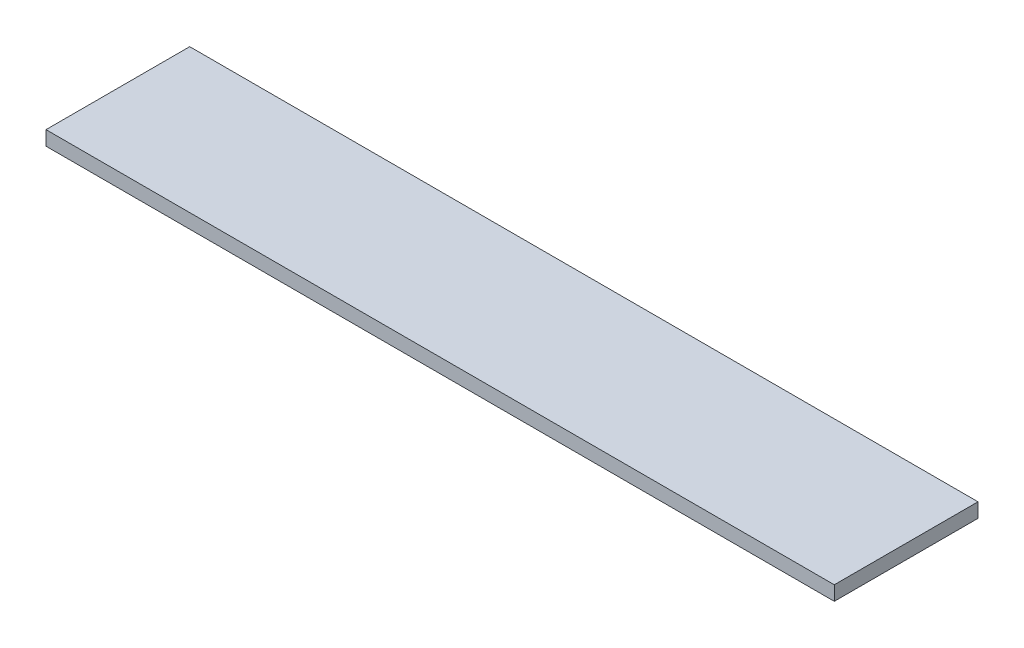
from build123d import *

# Parameters (mm, degrees)
SKETCH1_W           = 548.53
SKETCH1_H           = 100
BOSS_EXTRUDE1_DEPTH = 10


with BuildPart() as part:
    # Sketch1 → Boss-Extrude1 (new body)
    with BuildSketch(Plane(origin=(0, 0, 0), x_dir=(1, 0, 0), z_dir=(0, 1, 0))):
        Rectangle(SKETCH1_W, SKETCH1_H)
    extrude(amount=BOSS_EXTRUDE1_DEPTH)


solid = part.part
